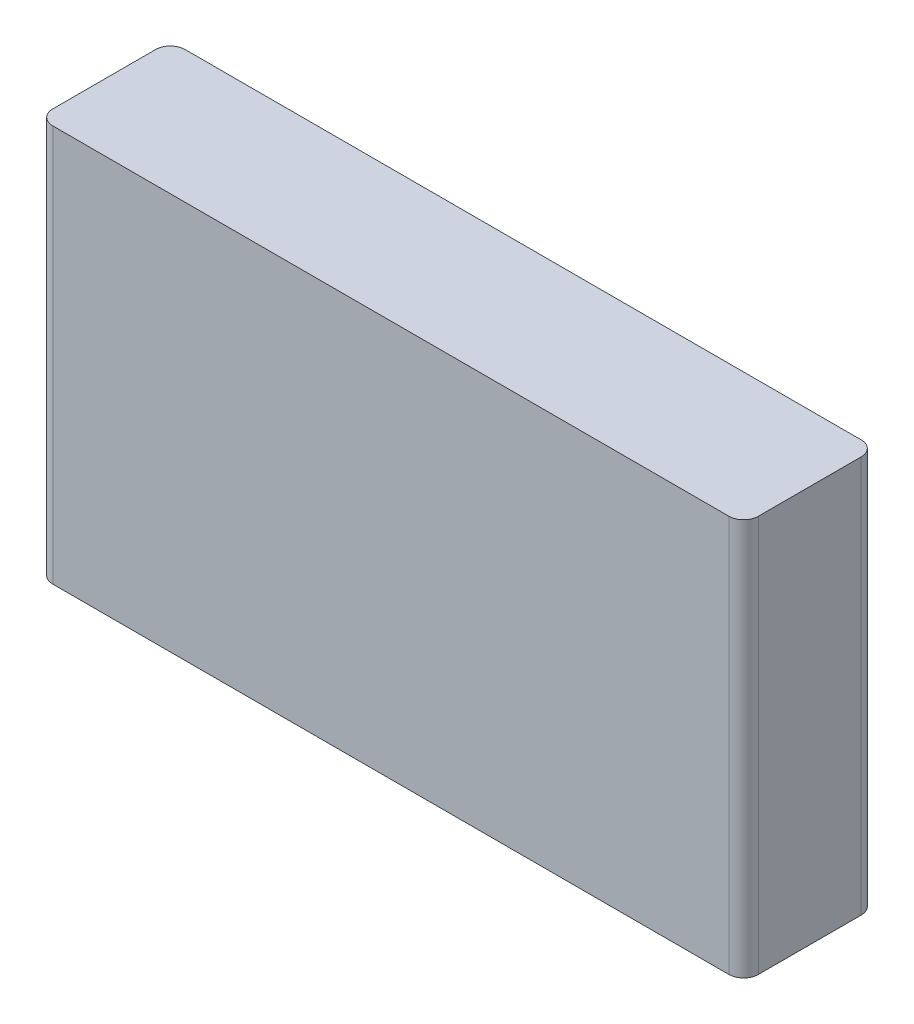
from build123d import *

# Parameters (mm, degrees)
SKETCH1_W           = 48
SKETCH1_H           = 27
BOSS_EXTRUDE1_DEPTH = 9
FILLET1_R           = 1


with BuildPart() as part:
    # Sketch1 → Boss-Extrude1 (new body)
    with BuildSketch(Plane.XY):
        Rectangle(SKETCH1_W, SKETCH1_H)
    extrude(amount=BOSS_EXTRUDE1_DEPTH)

    # Fillet1
    fillet1_edges = [part.edges().sort_by_distance(p)[0] for p in [
        (-24, 0, 9),
        (24, 0, 9),
        (-24, 0, 0),
        (24, 0, 0),
    ]]
    fillet(fillet1_edges, radius=FILLET1_R)


solid = part.part
